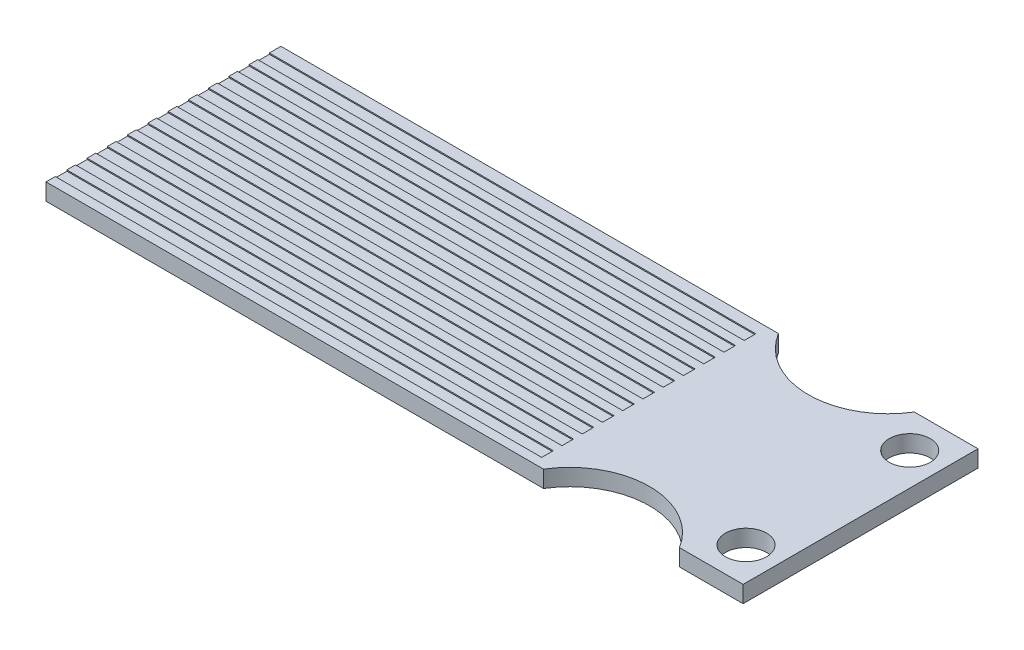
from build123d import *

# Parameters (mm, degrees)
BOSS_EXTRUDE1_DEPTH = 1.45
SKETCH2_R           = 1.775
CUT_EXTRUDE1_DEPTH  = 2.45
SKETCH3_W           = 42.044311255
SKETCH3_H           = 1
CUT_EXTRUDE2_DEPTH  = 0.1


with BuildPart() as part:
    # Sketch1 → Boss-Extrude1 (new body)
    with BuildSketch(Plane(origin=(0, 0, 0), x_dir=(1, 0, 0), z_dir=(0, 1, 0))):
        with BuildLine():
            Line((-30.125, -10.15), (12.875, -10.15))
            ThreePointArc((12.875, -10.15), (18.75, -6.862513487), (24.625, -10.15))
            Line((24.625, -10.15), (30.125, -10.15))
            Line((30.125, -10.15), (30.125, 10.15))
            Line((30.125, 10.15), (24.625, 10.15))
            ThreePointArc((24.625, 10.15), (18.75, 6.862513487), (12.875, 10.15))
            Line((12.875, 10.15), (-30.125, 10.15))
            Line((-30.125, 10.15), (-30.125, -10.15))
        make_face()
    extrude(amount=BOSS_EXTRUDE1_DEPTH)

    # Sketch2 → Cut-Extrude1 (cut, through all)
    with BuildSketch(Plane(origin=(0, 1.45, 0), x_dir=(1, 0, 0), z_dir=(0, 1, 0))):
        with Locations((27.3, 7.075)):
            Circle(SKETCH2_R)
        with Locations((27.3, -7.075)):
            Circle(SKETCH2_R)
    extrude(amount=-CUT_EXTRUDE1_DEPTH, mode=Mode.SUBTRACT)

    # Sketch3 → Cut-Extrude2 (cut)
    with BuildSketch(Plane(origin=(0, 1.45, 0), x_dir=(1, 0, 0), z_dir=(0, 1, 0))):
        with Locations((-9.102844373, 8.65)):
            Rectangle(SKETCH3_W, SKETCH3_H)
        with Locations((-9.102844373, 6.9)):
            Rectangle(SKETCH3_W, SKETCH3_H)
        with Locations((-9.102844373, 5.15)):
            Rectangle(SKETCH3_W, SKETCH3_H)
        with Locations((-9.102844373, 3.4)):
            Rectangle(SKETCH3_W, SKETCH3_H)
        with Locations((-9.102844373, 1.65)):
            Rectangle(SKETCH3_W, SKETCH3_H)
        with Locations((-9.102844373, -0.1)):
            Rectangle(SKETCH3_W, SKETCH3_H)
        with Locations((-9.102844373, -1.85)):
            Rectangle(SKETCH3_W, SKETCH3_H)
        with Locations((-9.102844373, -3.6)):
            Rectangle(SKETCH3_W, SKETCH3_H)
        with Locations((-9.102844373, -5.35)):
            Rectangle(SKETCH3_W, SKETCH3_H)
        with Locations((-9.102844373, -7.1)):
            Rectangle(SKETCH3_W, SKETCH3_H)
        with Locations((-9.102844373, -8.85)):
            Rectangle(SKETCH3_W, SKETCH3_H)
    extrude(amount=-CUT_EXTRUDE2_DEPTH, mode=Mode.SUBTRACT)


solid = part.part
